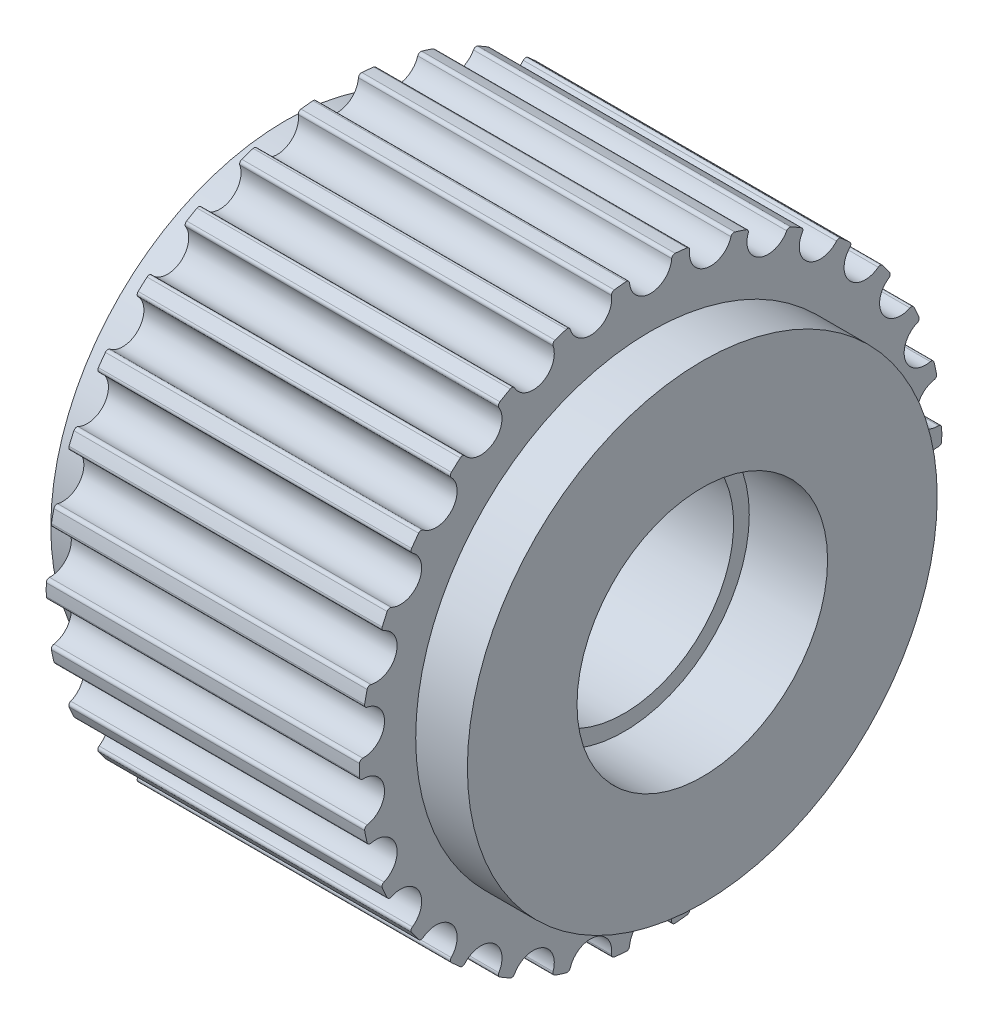
from build123d import *

# Parameters (mm, degrees)
CUT_EXTRUDE2_DEPTH       = 14.3
FILLET3_R                = 0.1
CIRPATTERN2_COUNT        = 30
FILLET3_OF_CIRPATTERN2_R = 0.1


with BuildPart() as part:
    # Sketch1 → Revolve1 (revolve)
    with BuildSketch(Plane.XY):
        Polygon((0, 4), (2.5, 4), (2.5, 3.5), (10.8, 3.5), (10.8, 4), (13.3, 4), (13.3, 7.5), (11.65, 7.5), (11.65, 9.295), (1.65, 9.295), (1.65, 7.5), (0, 7.5), align=None)
    revolve(axis=Axis((0, 0, 0), (1, 0, 0)))

    # Sketch3 → Cut-Extrude2 (cut, through all)
    with BuildSketch(Plane.ZY):
        with BuildLine():
            ThreePointArc((-0.673101026, 9.270596529), (0, 8.545), (0.673101026, 9.270596529))
            ThreePointArc((0.673101026, 9.270596529), (0, 9.295), (-0.673101026, 9.270596529))
        make_face()
    cut_extrude2 = extrude(amount=-CUT_EXTRUDE2_DEPTH, mode=Mode.SUBTRACT)

    # Fillet3
    fillet3_edges = [part.edges().sort_by_distance(p)[0] for p in [
        (6.65, 9.270596529, -0.673101026),
        (6.65, 9.270596529, 0.673101026),
    ]]
    fillet(fillet3_edges, radius=FILLET3_R)

    # CirPattern2: Cut-Extrude2 ×30 about axis
    cirpattern2_axis = Axis((0, 0, 0), (1, 0, 0))
    for i in range(1, CIRPATTERN2_COUNT):
        add(cut_extrude2.rotate(cirpattern2_axis, i * 360 / CIRPATTERN2_COUNT), mode=Mode.SUBTRACT)

    # Fillet3 of CirPattern2
    fillet3_of_cirpattern2_edges = [part.edges().sort_by_distance(p)[0] for p in [
        (6.65, 9.207957325, 1.269073246),
        (6.65, 8.92806618, 2.585857553),
        (6.65, 8.742886201, 3.155782927),
        (6.65, 8.195336497, 4.385599696),
        (6.65, 7.895708997, 4.904569751),
        (6.65, 7.104431284, 5.993670089),
        (6.65, 6.703451421, 6.439003342),
        (6.65, 5.703028332, 7.339788338),
        (6.65, 5.218220852, 7.69202159),
        (6.65, 4.052375677, 8.365122616),
        (6.65, 3.504928992, 8.608861583),
        (6.65, 2.224614759, 9.024860895),
        (6.65, 1.638454917, 9.149453016),
        (6.65, 0.299627501, 9.290169447),
        (6.65, -0.299627501, 9.290169447),
        (6.65, -1.638454917, 9.149453016),
        (6.65, -2.224614759, 9.024860895),
        (6.65, -3.504928992, 8.608861583),
        (6.65, -4.052375677, 8.365122616),
        (6.65, -5.218220852, 7.69202159),
        (6.65, -5.703028332, 7.339788338),
        (6.65, -6.703451421, 6.439003342),
        (6.65, -7.104431284, 5.993670089),
        (6.65, -7.895708997, 4.904569751),
        (6.65, -8.195336497, 4.385599696),
        (6.65, -8.742886201, 3.155782927),
        (6.65, -8.92806618, 2.585857553),
        (6.65, -9.207957325, 1.269073246),
        (6.65, -9.270596529, 0.673101026),
        (6.65, -9.270596529, -0.673101026),
        (6.65, -9.207957325, -1.269073246),
        (6.65, -8.92806618, -2.585857553),
        (6.65, -8.742886201, -3.155782927),
        (6.65, -8.195336497, -4.385599696),
        (6.65, -7.895708997, -4.904569751),
        (6.65, -7.104431284, -5.993670089),
        (6.65, -6.703451421, -6.439003342),
        (6.65, -5.703028332, -7.339788338),
        (6.65, -5.218220852, -7.69202159),
        (6.65, -4.052375677, -8.365122616),
        (6.65, -3.504928992, -8.608861583),
        (6.65, -2.224614759, -9.024860895),
        (6.65, -1.638454917, -9.149453016),
        (6.65, -0.299627501, -9.290169447),
        (6.65, 0.299627501, -9.290169447),
        (6.65, 1.638454917, -9.149453016),
        (6.65, 2.224614759, -9.024860895),
        (6.65, 3.504928992, -8.608861583),
        (6.65, 4.052375677, -8.365122616),
        (6.65, 5.218220852, -7.69202159),
        (6.65, 5.703028332, -7.339788338),
        (6.65, 6.703451421, -6.439003342),
        (6.65, 7.104431284, -5.993670089),
        (6.65, 7.895708997, -4.904569751),
        (6.65, 8.195336497, -4.385599696),
        (6.65, 8.742886201, -3.155782927),
        (6.65, 8.92806618, -2.585857553),
        (6.65, 9.207957325, -1.269073246),
    ]]
    fillet(fillet3_of_cirpattern2_edges, radius=FILLET3_OF_CIRPATTERN2_R)


solid = part.part
